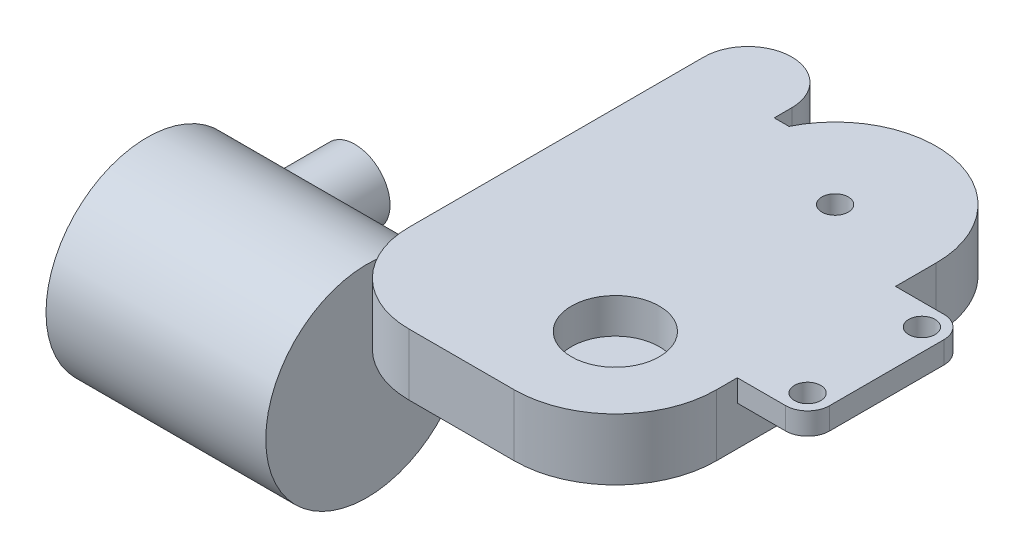
from build123d import *

# Parameters (mm, degrees)
BOSS_EXTRUDE1_DEPTH = 7
SKETCH2_R           = 2.5
CUT_EXTRUDE1_DEPTH  = 4
SKETCH3_R           = 1.5
SKETCH3_R_2         = 5
CUT_EXTRUDE2_DEPTH  = 4
SKETCH4_R           = 11.5
BOSS_EXTRUDE2_DEPTH = 25
SKETCH5_R           = 4
BOSS_EXTRUDE3_DEPTH = 11
SKETCH6_R           = 1.5
BOSS_EXTRUDE4_DEPTH = 2.5


with BuildPart() as part:
    # Sketch1 → Boss-Extrude1 (new body)
    with BuildSketch(Plane(origin=(0, 0, 0), x_dir=(1, 0, 0), z_dir=(0, 1, 0))):
        with BuildLine():
            Line((28.5, 13.628059387), (28.5, -11.371940613))
            ThreePointArc((28.5, -11.371940613), (25.131727984, -19.503668597), (17, -22.871940613))
            Line((17, -22.871940613), (5, -22.871940613))
            ThreePointArc((5, -22.871940613), (-2.071067812, -19.943008425), (-5, -12.871940613))
            Line((-5, -12.871940613), (-5, 20.70125692))
            ThreePointArc((-5, 20.70125692), (0, 25.70125692), (5, 20.70125692))
            Line((5, 20.70125692), (5, 18.70125692))
            Line((5, 18.70125692), (6.67950259, 18.70125692))
            ThreePointArc((6.67950259, 18.70125692), (19.604254191, 24.829303072), (28.5, 13.628059387))
        make_face()
    extrude(amount=BOSS_EXTRUDE1_DEPTH)

    # Sketch2 → Cut-Extrude1 (cut)
    with BuildSketch(Plane.XZ):
        with Locations((0, -20.70125692)):
            Circle(SKETCH2_R)
    extrude(amount=-CUT_EXTRUDE1_DEPTH, mode=Mode.SUBTRACT)

    # Sketch3 → Cut-Extrude2 (cut)
    with BuildSketch(Plane(origin=(0, 7, 0), x_dir=(1, 0, 0), z_dir=(0, 1, 0))):
        with Locations((17, 13.628059387)):
            Circle(SKETCH3_R)
        with Locations((17, -11.371940613)):
            Circle(SKETCH3_R_2)
    extrude(amount=-CUT_EXTRUDE2_DEPTH, mode=Mode.SUBTRACT)

    # Sketch4 → Boss-Extrude2 (add)
    with BuildSketch(Plane.ZY.offset(5)):
        with Locations((17.637770726, -5.75)):
            Circle(SKETCH4_R)
    extrude(amount=BOSS_EXTRUDE2_DEPTH)

    # Sketch5 → Boss-Extrude3 (add)
    with BuildSketch(Plane.XY.offset(10)):
        with Locations((-25, -5.75)):
            Circle(SKETCH5_R)
    extrude(amount=-BOSS_EXTRUDE3_DEPTH)

    # Sketch6 → Boss-Extrude4 (add)
    with BuildSketch(Plane(origin=(0, 7, 0), x_dir=(1, 0, 0), z_dir=(0, 1, 0))):
        with BuildLine():
            Line((28.5, 9), (34, 9))
            ThreePointArc((34, 9), (35.767766953, 8.267766953), (36.5, 6.5))
            Line((36.5, 6.5), (36.5, -6.5))
            ThreePointArc((36.5, -6.5), (35.767766953, -8.267766953), (34, -9))
            Line((34, -9), (28.5, -9))
            Line((28.5, -9), (28.5, 9))
        make_face()
        with Locations((34, -6.5)):
            Circle(SKETCH6_R, mode=Mode.SUBTRACT)
        with Locations((34, 6.5)):
            Circle(SKETCH6_R, mode=Mode.SUBTRACT)
    extrude(amount=-BOSS_EXTRUDE4_DEPTH)


solid = part.part
